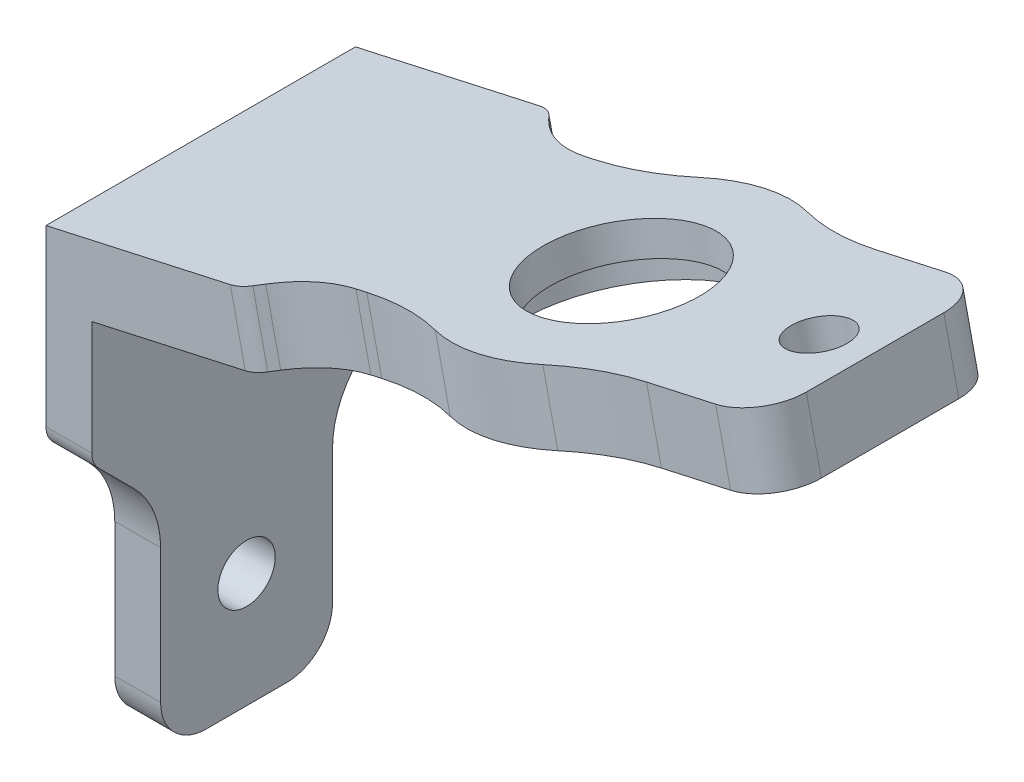
from build123d import *

# Parameters (mm, degrees)
BOSS_EXTRUDE1_DEPTH     = 3
BOSS_EXTRUDE2_DEPTH     = 2
CUT_EXTRUDE1_DEPTH      = 7.75
CUT_EXTRUDE1_DEPTH_BACK = 7.75
SKETCH5_R               = 1.25
CUT_EXTRUDE2_DEPTH      = 31.070572477
SKETCH6_R               = 1.25
CUT_EXTRUDE3_DEPTH      = 27.558218913
SKETCH7_R               = 3.5
CUT_EXTRUDE4_DEPTH      = 27.558218913
SKETCH10_R              = 6.25
SKETCH10_R_2            = 3.5
BOSS_EXTRUDE3_DEPTH     = 3
SKETCH8_R               = 5.15
CUT_EXTRUDE5_DEPTH      = 1.6
FILLET1_R               = 10


with BuildPart() as part:
    # Sketch2 → Boss-Extrude1 (new body)
    with BuildSketch(Plane(origin=(-8.299779748, 37.326456989, 0), x_dir=(0.976159298, 0.21705535, 0), z_dir=(-0.21705535, 0.976159298, 0))):
        with BuildLine():
            Line((-4.14298056, 6.75), (-8.912705405, 6.75))
            Line((-8.912705405, 6.75), (-8.912705405, -6.75))
            Line((-8.912705405, -6.75), (-4.14298056, -6.75))
            Line((-4.14298056, -6.75), (-3.64298056, -6.75))
            Line((-3.64298056, -6.75), (-2.057194122, -6.75))
            ThreePointArc((-2.057194122, -6.75), (-1.67451069, -6.673879533), (-1.350087341, -6.457106781))
            Line((-1.350087341, -6.457106781), (-1.064553435, -6.171572875))
            ThreePointArc((-1.064553435, -6.171572875), (0.23313996, -5.30448187), (1.76387369, -5))
            Line((1.76387369, -5), (14.343433612, -5))
            Line((14.343433612, -5), (14.843433612, -5))
            Line((14.843433612, -5), (17.843433612, -5))
            ThreePointArc((17.843433612, -5), (19.257647174, -4.414213562), (19.843433612, -3))
            Line((19.843433612, -3), (19.843433612, 3))
            ThreePointArc((19.843433612, 3), (19.257647174, 4.414213562), (17.843433612, 5))
            Line((17.843433612, 5), (14.843433612, 5))
            Line((14.843433612, 5), (14.343433612, 5))
            Line((14.343433612, 5), (1.76387369, 5))
            ThreePointArc((1.76387369, 5), (0.23313996, 5.30448187), (-1.064553435, 6.171572875))
            Line((-1.064553435, 6.171572875), (-1.350087341, 6.457106781))
            ThreePointArc((-1.350087341, 6.457106781), (-1.67451069, 6.673879533), (-2.057194122, 6.75))
            Line((-2.057194122, 6.75), (-3.64298056, 6.75))
            Line((-3.64298056, 6.75), (-4.14298056, 6.75))
        make_face()
    extrude(amount=BOSS_EXTRUDE1_DEPTH)

    # Sketch3 → Boss-Extrude2 (add)
    with BuildSketch(Plane.ZY.offset(17)):
        with BuildLine():
            Line((-6.75, 35.391906601), (-6.75, 38.320384496))
            Line((-6.75, 38.320384496), (6.75, 38.320384496))
            Line((6.75, 38.320384496), (6.75, 35.391906601))
            Line((6.75, 35.391906601), (6.75, 30.414213562))
            ThreePointArc((6.75, 30.414213562), (6.673879533, 30.03153013), (6.457106781, 29.707106781))
            Line((6.457106781, 29.707106781), (4.921572875, 28.171572875))
            ThreePointArc((4.921572875, 28.171572875), (4.05448187, 26.87387948), (3.75, 25.343145751))
            Line((3.75, 25.343145751), (3.75, 20.3))
            Line((3.75, 20.3), (3.75, 19.8))
            Line((3.75, 19.8), (3.75, 19.5))
            ThreePointArc((3.75, 19.5), (3.164213562, 18.085786438), (1.75, 17.5))
            Line((1.75, 17.5), (-1.75, 17.5))
            ThreePointArc((-1.75, 17.5), (-3.164213562, 18.085786438), (-3.75, 19.5))
            Line((-3.75, 19.5), (-3.75, 19.8))
            Line((-3.75, 19.8), (-3.75, 20.3))
            Line((-3.75, 20.3), (-3.75, 25.343145751))
            ThreePointArc((-3.75, 25.343145751), (-4.05448187, 26.87387948), (-4.921572875, 28.171572875))
            Line((-4.921572875, 28.171572875), (-6.457106781, 29.707106781))
            ThreePointArc((-6.457106781, 29.707106781), (-6.673879533, 30.03153013), (-6.75, 30.414213562))
            Line((-6.75, 30.414213562), (-6.75, 35.391906601))
        make_face()
    extrude(amount=BOSS_EXTRUDE2_DEPTH)

    # Sketch4 → Cut-Extrude1 (cut, two sides)
    with BuildSketch(Plane.XY) as cut_extrude1_sk:
        Polygon((-17.651166049, 38.320384496), (-19, 38.02046252), (-19, 38.320384496), align=None)
    extrude(amount=CUT_EXTRUDE1_DEPTH, mode=Mode.SUBTRACT)
    extrude(cut_extrude1_sk.sketch, amount=-CUT_EXTRUDE1_DEPTH_BACK, mode=Mode.SUBTRACT)

    # Sketch5 → Cut-Extrude2 (cut, through all)
    with BuildSketch(Plane.ZY.offset(19)):
        with Locations((0, 22.5)):
            Circle(SKETCH5_R)
    extrude(amount=-CUT_EXTRUDE2_DEPTH, mode=Mode.SUBTRACT)

    # Sketch6 → Cut-Extrude3 (cut, through all)
    with BuildSketch(Plane(origin=(-8.950945797, 40.254934884, 0), x_dir=(0.976159298, 0.21705535, 0), z_dir=(-0.21705535, 0.976159298, 0))):
        with Locations((17.343433612, 0)):
            Circle(SKETCH6_R)
    extrude(amount=-CUT_EXTRUDE3_DEPTH, mode=Mode.SUBTRACT)

    # Sketch7 → Cut-Extrude4 (cut, through all)
    with BuildSketch(Plane(origin=(-8.950945797, 40.254934884, 0), x_dir=(0.976159298, 0.21705535, 0), z_dir=(-0.21705535, 0.976159298, 0))):
        with Locations((8.502484958, 0)):
            Circle(SKETCH7_R)
    extrude(amount=-CUT_EXTRUDE4_DEPTH, mode=Mode.SUBTRACT)

    # Sketch10 → Boss-Extrude3 (add)
    with BuildSketch(Plane(origin=(-8.950945797, 40.254934884, 0), x_dir=(0.976159298, 0.21705535, 0), z_dir=(-0.21705535, 0.976159298, 0))):
        with Locations((8.502484958, 0)):
            Circle(SKETCH10_R)
        with Locations((8.502484958, 0)):
            Circle(SKETCH10_R_2, mode=Mode.SUBTRACT)
    extrude(amount=-BOSS_EXTRUDE3_DEPTH)

    # Sketch8 → Cut-Extrude5 (cut)
    with BuildSketch(Plane(origin=(-8.299779748, 37.326456989, 0), x_dir=(0.976159298, 0.21705535, 0), z_dir=(0.21705535, -0.976159298, 0))):
        with Locations((8.502484958, 0)):
            Circle(SKETCH8_R)
    extrude(amount=-CUT_EXTRUDE5_DEPTH, mode=Mode.SUBTRACT)

    # Fillet1
    fillet1_edges = [part.edges().sort_by_distance(p)[0] for p in [
        (-3.986180392, 39.822248221, 5),
        (-3.986180392, 39.822248221, -5),
        (3.335014343, 41.450163343, 5),
        (3.335014343, 41.450163343, -5),
    ]]
    fillet(fillet1_edges, radius=FILLET1_R)


solid = part.part
